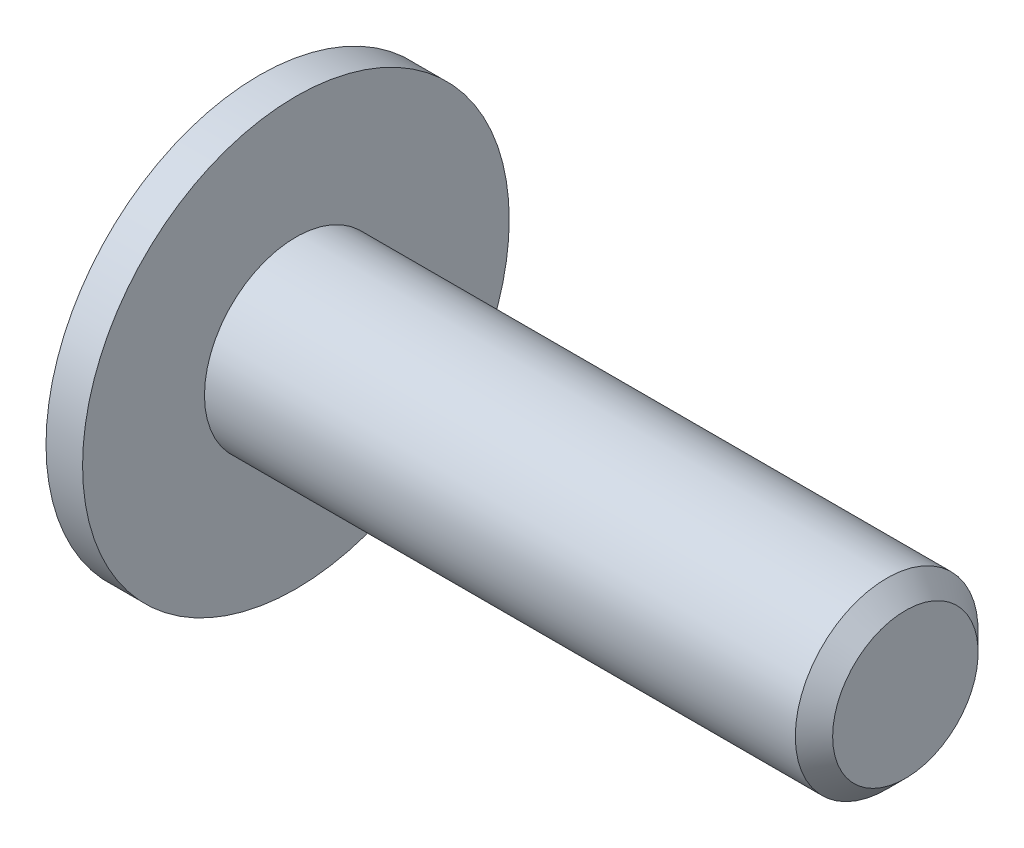
from build123d import *

# Parameters (mm, degrees)
CUT_EXTRUDE1_DEPTH = 1.05


with BuildPart() as part:
    # Sketch1 → Revolve1 (revolve)
    with BuildSketch(Plane.XY):
        with BuildLine():
            Line((-1.65, 0), (-1.65, 1.95))
            ThreePointArc((-1.65, 1.95), (-1.184849394, 2.371679791), (-0.6, 2.6))
            Line((-0.6, 2.6), (-0.6, 3.5))
            Line((-0.6, 3.5), (0, 3.5))
            Line((0, 3.5), (0, 1.5))
            Line((0, 1.5), (9.6935, 1.5))
            Line((9.6935, 1.5), (10, 1.1935))
            Line((10, 1.1935), (10, 0))
            Line((10, 0), (-1.65, 0))
        make_face()
    revolve(axis=Axis((10, 0, 0), (-1, 0, 0)))

    # Sketch2 → Cut-Extrude1 (cut)
    with BuildSketch(Plane(origin=(-1.65, 0, 0), x_dir=(0, 0, -1), z_dir=(1, 0, 0))):
        Polygon((-1, -0.577350269), (0, -1.154700538), (1, -0.577350269), (1, 0.577350269), (0, 1.154700538), (-1, 0.577350269), align=None)
    extrude(amount=CUT_EXTRUDE1_DEPTH, mode=Mode.SUBTRACT)


solid = part.part
